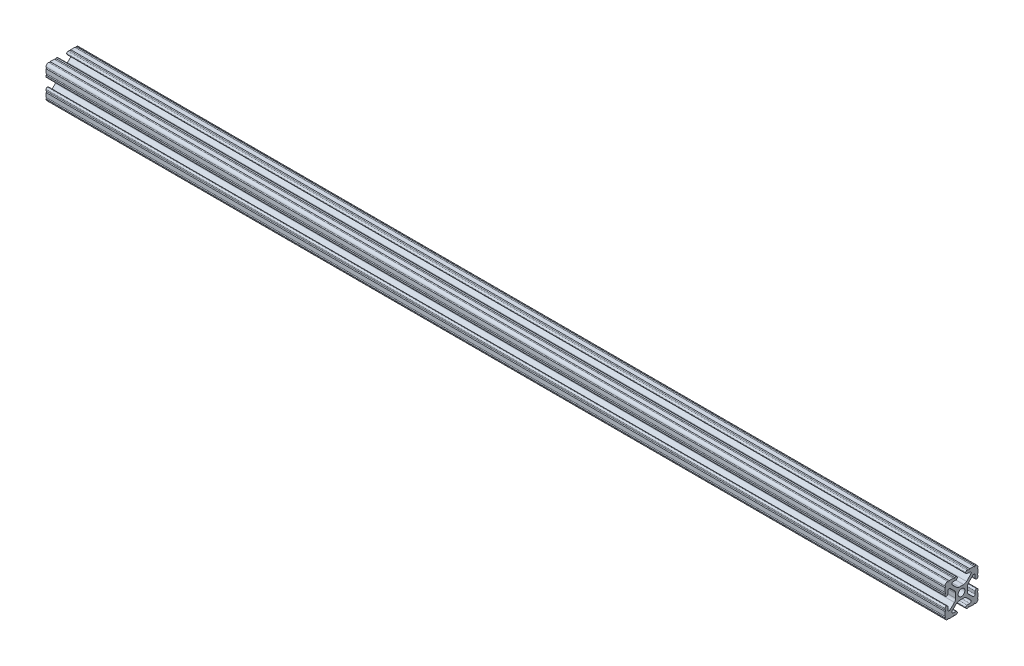
from build123d import *

# Parameters (mm, degrees)
SKETCH1_R           = 2.6035
BOSS_EXTRUDE1_DEPTH = 346.075


with BuildPart() as part:
    # Sketch1 → Boss-Extrude1 (new body, symmetric)
    with BuildSketch(Plane(origin=(0, 0, 0), x_dir=(0, 0, -1), z_dir=(1, 0, 0))):
        with BuildLine():
            Line((6.333126718, -12.7), (9.550443118, -12.7))
            ThreePointArc((9.550443118, -12.7), (10.058366869, -12.192000006), (10.566443095, -12.699847501))
            ThreePointArc((10.566443095, -12.699847501), (12.082537762, -12.08250727), (12.699846982, -10.566399977))
            ThreePointArc((12.699846982, -10.566399977), (12.192000006, -10.058323491), (12.7, -9.5504))
            Line((12.7, -9.5504), (12.7, -6.3330836))
            ThreePointArc((12.7, -6.3330836), (12.192, -5.8250836), (12.7, -5.3170836))
            Line((12.7, -5.3170836), (12.7, -4.287469289))
            ThreePointArc((12.7, -4.287469289), (12.39275138, -3.545705502), (11.650987593, -3.238456882))
            Line((11.650987593, -3.238456882), (11.539212407, -3.238456882))
            ThreePointArc((11.539212407, -3.238456882), (10.79744862, -3.545705502), (10.4902, -4.287469289))
            Line((10.4902, -4.287469289), (10.4902, -6.402089023))
            ThreePointArc((10.4902, -6.402089023), (9.856505071, -7.351067942), (8.737131347, -7.129408934))
            Line((8.737131347, -7.129408934), (5.441005833, -3.840816462))
            ThreePointArc((5.441005833, -3.840816462), (4.750877967, -2.809883091), (4.5085, -1.593185507))
            Line((4.5085, -1.593185507), (4.5085, 1.593185507))
            ThreePointArc((4.5085, 1.593185507), (4.750877967, 2.809883091), (5.441005833, 3.840816462))
            Line((5.441005833, 3.840816462), (8.737131347, 7.129408934))
            ThreePointArc((8.737131347, 7.129408934), (9.856505071, 7.351067942), (10.4902, 6.402089023))
            Line((10.4902, 6.402089023), (10.4902, 4.287469289))
            ThreePointArc((10.4902, 4.287469289), (10.79744862, 3.545705502), (11.539212407, 3.238456882))
            Line((11.539212407, 3.238456882), (11.650987593, 3.238456882))
            ThreePointArc((11.650987593, 3.238456882), (12.39275138, 3.545705502), (12.7, 4.287469289))
            Line((12.7, 4.287469289), (12.7, 5.3170836))
            ThreePointArc((12.7, 5.3170836), (12.192, 5.8250836), (12.7, 6.3330836))
            Line((12.7, 6.3330836), (12.7, 9.5504))
            ThreePointArc((12.7, 9.5504), (12.192000006, 10.058323491), (12.699846982, 10.566399977))
            ThreePointArc((12.699846982, 10.566399977), (12.082537762, 12.08250727), (10.566443095, 12.699847501))
            ThreePointArc((10.566443095, 12.699847501), (10.058366869, 12.192000006), (9.550443118, 12.7))
            Line((9.550443118, 12.7), (6.333126718, 12.7))
            ThreePointArc((6.333126718, 12.7), (5.825126718, 12.192), (5.317126718, 12.7))
            Line((5.317126718, 12.7), (4.287512407, 12.7))
            ThreePointArc((4.287512407, 12.7), (3.54574862, 12.39275138), (3.2385, 11.650987593))
            Line((3.2385, 11.650987593), (3.2385, 11.539212407))
            ThreePointArc((3.2385, 11.539212407), (3.54574862, 10.79744862), (4.287512407, 10.4902))
            Line((4.287512407, 10.4902), (6.476788598, 10.4902))
            ThreePointArc((6.476788598, 10.4902), (7.432222385, 9.85140422), (7.207036008, 8.724370562))
            Line((7.207036008, 8.724370562), (3.898272566, 5.423169045))
            ThreePointArc((3.898272566, 5.423169045), (2.869120213, 4.736787962), (1.655778399, 4.4958))
            Line((1.655778399, 4.4958), (-1.655778399, 4.4958))
            ThreePointArc((-1.655778399, 4.4958), (-2.869120213, 4.736787962), (-3.898272566, 5.423169045))
            Line((-3.898272566, 5.423169045), (-7.207036008, 8.724370562))
            ThreePointArc((-7.207036008, 8.724370562), (-7.432222385, 9.85140422), (-6.476788598, 10.4902))
            Line((-6.476788598, 10.4902), (-4.287512407, 10.4902))
            ThreePointArc((-4.287512407, 10.4902), (-3.54574862, 10.79744862), (-3.2385, 11.539212407))
            Line((-3.2385, 11.539212407), (-3.2385, 11.650987593))
            ThreePointArc((-3.2385, 11.650987593), (-3.54574862, 12.39275138), (-4.287512407, 12.7))
            Line((-4.287512407, 12.7), (-5.317126718, 12.7))
            ThreePointArc((-5.317126718, 12.7), (-5.825126718, 12.192), (-6.333126718, 12.7))
            Line((-6.333126718, 12.7), (-9.550443118, 12.7))
            ThreePointArc((-9.550443118, 12.7), (-10.058366869, 12.192000006), (-10.566443095, 12.699847501))
            ThreePointArc((-10.566443095, 12.699847501), (-12.082537762, 12.08250727), (-12.699846982, 10.566399977))
            ThreePointArc((-12.699846982, 10.566399977), (-12.192000006, 10.058323491), (-12.7, 9.5504))
            Line((-12.7, 9.5504), (-12.7, 6.3330836))
            ThreePointArc((-12.7, 6.3330836), (-12.192, 5.8250836), (-12.7, 5.3170836))
            Line((-12.7, 5.3170836), (-12.7, 4.287469289))
            ThreePointArc((-12.7, 4.287469289), (-12.39275138, 3.545705502), (-11.650987593, 3.238456882))
            Line((-11.650987593, 3.238456882), (-11.539212407, 3.238456882))
            ThreePointArc((-11.539212407, 3.238456882), (-10.79744862, 3.545705502), (-10.4902, 4.287469289))
            Line((-10.4902, 4.287469289), (-10.4902, 6.402089023))
            ThreePointArc((-10.4902, 6.402089023), (-9.856505071, 7.351067942), (-8.737131347, 7.129408934))
            Line((-8.737131347, 7.129408934), (-5.441005833, 3.840816462))
            ThreePointArc((-5.441005833, 3.840816462), (-4.750877967, 2.809883091), (-4.5085, 1.593185507))
            Line((-4.5085, 1.593185507), (-4.5085, -1.593185507))
            ThreePointArc((-4.5085, -1.593185507), (-4.750877967, -2.809883091), (-5.441005833, -3.840816462))
            Line((-5.441005833, -3.840816462), (-8.737131347, -7.129408934))
            ThreePointArc((-8.737131347, -7.129408934), (-9.856505071, -7.351067942), (-10.4902, -6.402089023))
            Line((-10.4902, -6.402089023), (-10.4902, -4.287469289))
            ThreePointArc((-10.4902, -4.287469289), (-10.79744862, -3.545705502), (-11.539212407, -3.238456882))
            Line((-11.539212407, -3.238456882), (-11.650987593, -3.238456882))
            ThreePointArc((-11.650987593, -3.238456882), (-12.39275138, -3.545705502), (-12.7, -4.287469289))
            Line((-12.7, -4.287469289), (-12.7, -5.3170836))
            ThreePointArc((-12.7, -5.3170836), (-12.192, -5.8250836), (-12.7, -6.3330836))
            Line((-12.7, -6.3330836), (-12.7, -9.5504))
            ThreePointArc((-12.7, -9.5504), (-12.192000006, -10.058323491), (-12.699846982, -10.566399977))
            ThreePointArc((-12.699846982, -10.566399977), (-12.082537762, -12.08250727), (-10.566443095, -12.699847501))
            ThreePointArc((-10.566443095, -12.699847501), (-10.058366869, -12.192000006), (-9.550443118, -12.7))
            Line((-9.550443118, -12.7), (-6.333126718, -12.7))
            ThreePointArc((-6.333126718, -12.7), (-5.825126718, -12.192), (-5.317126718, -12.7))
            Line((-5.317126718, -12.7), (-4.287512407, -12.7))
            ThreePointArc((-4.287512407, -12.7), (-3.54574862, -12.39275138), (-3.2385, -11.650987593))
            Line((-3.2385, -11.650987593), (-3.2385, -11.539212407))
            ThreePointArc((-3.2385, -11.539212407), (-3.54574862, -10.79744862), (-4.287512407, -10.4902))
            Line((-4.287512407, -10.4902), (-6.416408329, -10.4902))
            ThreePointArc((-6.416408329, -10.4902), (-7.41473083, -9.822813117), (-7.179650497, -8.645192506))
            Line((-7.179650497, -8.645192506), (-3.952270251, -5.423690499))
            ThreePointArc((-3.952270251, -5.423690499), (-2.922936451, -4.736929036), (-1.709253557, -4.4958))
            Line((-1.709253557, -4.4958), (1.709253557, -4.4958))
            ThreePointArc((1.709253557, -4.4958), (2.922936451, -4.736929036), (3.952270251, -5.423690499))
            Line((3.952270251, -5.423690499), (7.179650497, -8.645192506))
            ThreePointArc((7.179650497, -8.645192506), (7.41473083, -9.822813117), (6.416408329, -10.4902))
            Line((6.416408329, -10.4902), (4.287512407, -10.4902))
            ThreePointArc((4.287512407, -10.4902), (3.54574862, -10.79744862), (3.2385, -11.539212407))
            Line((3.2385, -11.539212407), (3.2385, -11.650987593))
            ThreePointArc((3.2385, -11.650987593), (3.54574862, -12.39275138), (4.287512407, -12.7))
            Line((4.287512407, -12.7), (5.317126718, -12.7))
            ThreePointArc((5.317126718, -12.7), (5.825126718, -12.192), (6.333126718, -12.7))
        make_face()
        Circle(SKETCH1_R, mode=Mode.SUBTRACT)
    extrude(amount=BOSS_EXTRUDE1_DEPTH, both=True)


solid = part.part
